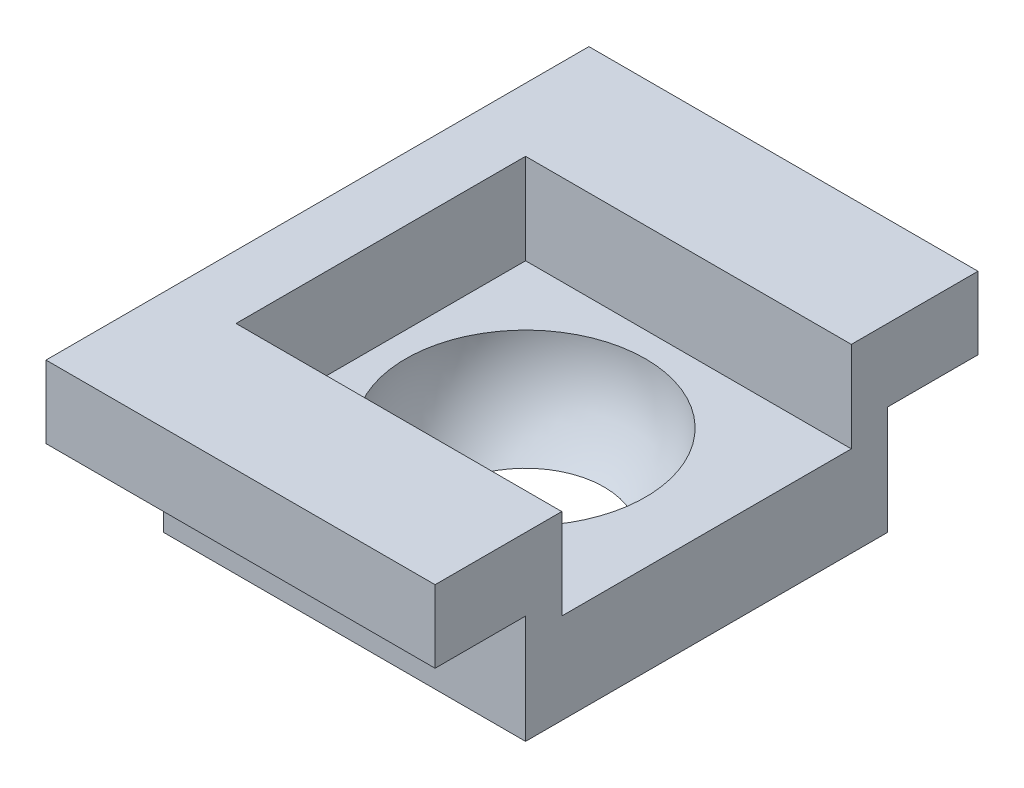
from build123d import *

# Parameters (mm, degrees)
SKETCH1_W           = 4
SKETCH1_H           = 4
BOSS_EXTRUDE1_DEPTH = 2
SKETCH3_W           = 6.995739113
SKETCH3_H           = 4.795831112
CUT_EXTRUDE1_DEPTH  = 1
BOSS_EXTRUDE2_DEPTH = 1
SKETCH5_W           = 4
SKETCH5_H           = 0.8
BOSS_EXTRUDE3_DEPTH = 1
SKETCH6_W           = 4
SKETCH6_H           = 0.8
BOSS_EXTRUDE4_DEPTH = 1
SKETCH9_W           = 6
SKETCH9_H           = 0.8
BOSS_EXTRUDE6_DEPTH = 0.3


with BuildPart() as part:
    # Sketch1 → Boss-Extrude1 (new body)
    with BuildSketch(Plane(origin=(0, 0, 0), x_dir=(1, 0, 0), z_dir=(0, 1, 0))):
        with Locations((-0.305984445, 0.016020496)):
            Rectangle(SKETCH1_W, SKETCH1_H)
    extrude(amount=BOSS_EXTRUDE1_DEPTH)

    # Sketch2 → Cut-Revolve1 (revolve, cut)
    with BuildSketch(Plane(origin=(0, 2, 0), x_dir=(1, 0, 0), z_dir=(0, 1, 0))):
        with BuildLine():
            Line((-0.305984445, -1.308979504), (-0.305984445, 1.341020496))
            ThreePointArc((-0.305984445, 1.341020496), (-1.630984445, 0.016020496), (-0.305984445, -1.308979504))
        make_face()
    revolve(axis=Axis((-0.305984445, 2, 1.308979504), (0, 0, -1)), mode=Mode.SUBTRACT)

    # Sketch3 → Cut-Extrude1 (cut)
    with BuildSketch(Plane.XZ):
        with Locations((-1.219435612, 0.226207457)):
            Rectangle(SKETCH3_W, SKETCH3_H)
    extrude(amount=-CUT_EXTRUDE1_DEPTH, mode=Mode.SUBTRACT)

    # Sketch4 → Boss-Extrude2 (add)
    with BuildSketch(Plane(origin=(0, 2, 0), x_dir=(1, 0, 0), z_dir=(0, 1, 0))):
        Polygon((-1.905984445, -1.583979504), (1.515020657, -1.583979504), (1.694015555, -1.583979504), (1.694015555, -1.983979504), (-2.305984445, -1.983979504), (-2.305984445, 2.016020496), (1.694015555, 2.016020496), (1.694015555, 1.616020496), (1.515020657, 1.616020496), (-1.905984445, 1.616020496), align=None)
    extrude(amount=BOSS_EXTRUDE2_DEPTH)

    # Sketch5 → Boss-Extrude3 (add)
    with BuildSketch(Plane.XY.offset(1.983979504)):
        with Locations((-0.305984445, 2.6)):
            Rectangle(SKETCH5_W, SKETCH5_H)
    extrude(amount=BOSS_EXTRUDE3_DEPTH)

    # Sketch6 → Boss-Extrude4 (add)
    with BuildSketch(Plane(origin=(0, 0, -2.016020496), x_dir=(-1, 0, 0), z_dir=(0, 0, -1))):
        with Locations((0.305984445, 2.6)):
            Rectangle(SKETCH6_W, SKETCH6_H)
    extrude(amount=BOSS_EXTRUDE4_DEPTH)

    # Sketch9 → Boss-Extrude6 (add)
    with BuildSketch(Plane.ZY.offset(2.305984445)):
        with Locations((-0.016020496, 2.6)):
            Rectangle(SKETCH9_W, SKETCH9_H)
    extrude(amount=BOSS_EXTRUDE6_DEPTH)


solid = part.part
